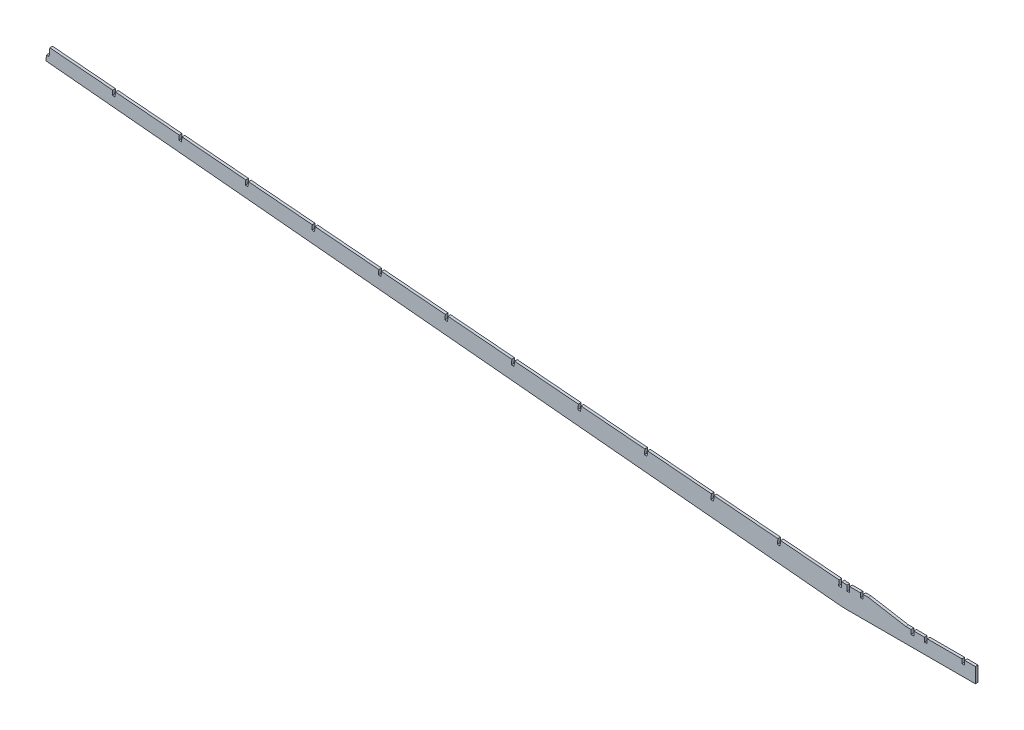
from build123d import *

# Parameters (mm, degrees)
BOSS_EXTRUDE1_DEPTH = 3.175
CUT_EXTRUDE1_DEPTH  = 4.175


with BuildPart() as part:
    # Sketch1 → Boss-Extrude1 (new body)
    with BuildSketch(Plane.XY):
        Polygon((-950.530495659, 69.619322302), (-951.061849964, 63.291592645), (-11.536706102, -24.902638492), (-8.372841274, -25.168315645), (0, -25.545856054), (152.4, -25.545856054), (152.4, -7.765856054), (139.7, -7.765856054), (139.7, -12.845856054), (136.525, -12.845856054), (136.525, -7.765856054), (95.25, -7.765856054), (95.25, -12.845856054), (92.075, -12.845856054), (92.075, -7.765856054), (79.375, -7.765856054), (79.375, -12.845856054), (76.2, -12.845856054), (76.2, -7.765856054), (69.85, -7.765856054), (25.4, -0.145856054), (19.05, -0.145856054), (19.05, -5.225856054), (15.875, -5.225856054), (15.875, -0.145856054), (3.175, -0.145856054), (3.175, -6.495856054), (0, -6.495856054), (0, -0.145856054), (-2.81225704, -0.145856054), (-6.247424053, 0.14260298), (-6.778778359, -6.185126677), (-9.942643187, -5.919449524), (-9.411288881, 0.408280132), (-946.54805097, 79.101852726), (-947.366630831, 69.353645149), align=None)
    extrude(amount=BOSS_EXTRUDE1_DEPTH)

    # Sketch2 → Cut-Extrude1 (cut, through all)
    with BuildSketch(Plane.XY.offset(3.175)):
        Polygon((-79.415081651, -0.013332249), (-78.889760507, 6.242550403), (-82.053625335, 6.508227555), (-82.578671745, 0.255616625), align=None)
        Polygon((-158.378290396, 6.699631648), (-157.859826617, 12.873852131), (-161.023691445, 13.139529284), (-161.54188049, 6.968580522), align=None)
        Polygon((-237.341499142, 13.412595546), (-236.829892727, 19.50515386), (-239.993757555, 19.770831012), (-240.505089236, 13.68154442), align=None)
        Polygon((-316.304707888, 20.125559443), (-315.799958836, 26.136455588), (-318.963823664, 26.402132741), (-319.468297982, 20.394508317), align=None)
        Polygon((-395.267916634, 26.83852334), (-394.770024946, 32.767757316), (-397.933889774, 33.033434469), (-398.431506728, 27.107472214), align=None)
        Polygon((-474.23112538, 33.551487238), (-473.740091056, 39.399059045), (-476.903955884, 39.664736197), (-477.394715474, 33.820436112), align=None)
        Polygon((-553.194334126, 40.264451135), (-552.710157166, 46.030360773), (-555.874021994, 46.296037926), (-556.35792422, 40.533400009), align=None)
        Polygon((-632.157542872, 46.977415032), (-631.680223276, 52.661662502), (-634.844088104, 52.927339654), (-635.321132966, 47.246363906), align=None)
        Polygon((-711.120751618, 53.69037893), (-710.650289385, 59.29296423), (-713.814154213, 59.558641383), (-714.284341712, 53.959327804), align=None)
        Polygon((-790.083960364, 60.403342827), (-789.620355495, 65.924265958), (-792.784220323, 66.189943111), (-793.247550458, 60.672291701), align=None)
        Polygon((-869.047169109, 67.116306724), (-868.590421605, 72.555567687), (-871.754286433, 72.821244839), (-872.210759203, 67.385255598), align=None)
    extrude(amount=-CUT_EXTRUDE1_DEPTH, mode=Mode.SUBTRACT)


solid = part.part
